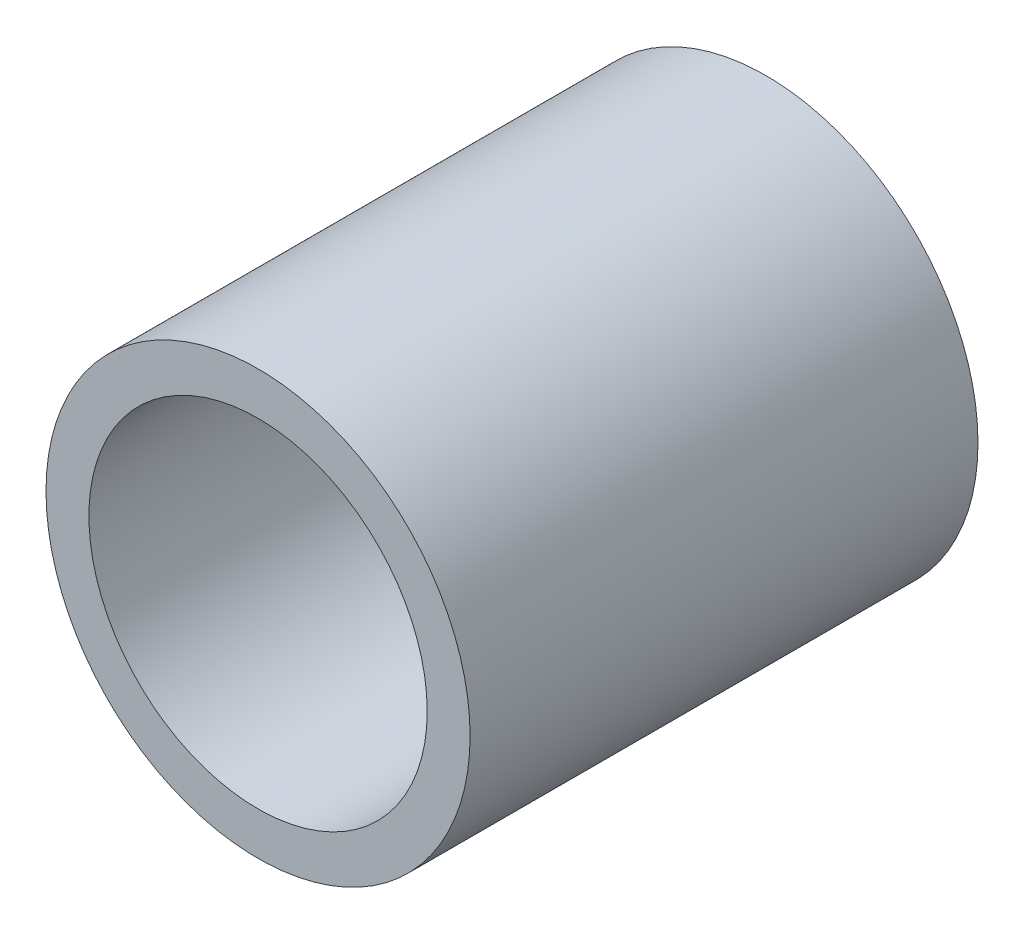
from build123d import *

# Parameters (mm, degrees)
SKETCH1_R           = 16.7005
SKETCH1_R_2         = 13.3223
EXTRUDE_THIN1_DEPTH = 20


with BuildPart() as part:
    # Sketch1 → Extrude-Thin1 (new body, symmetric)
    with BuildSketch(Plane.XY):
        Circle(SKETCH1_R)
        Circle(SKETCH1_R_2, mode=Mode.SUBTRACT)
    extrude(amount=EXTRUDE_THIN1_DEPTH, both=True)


solid = part.part
